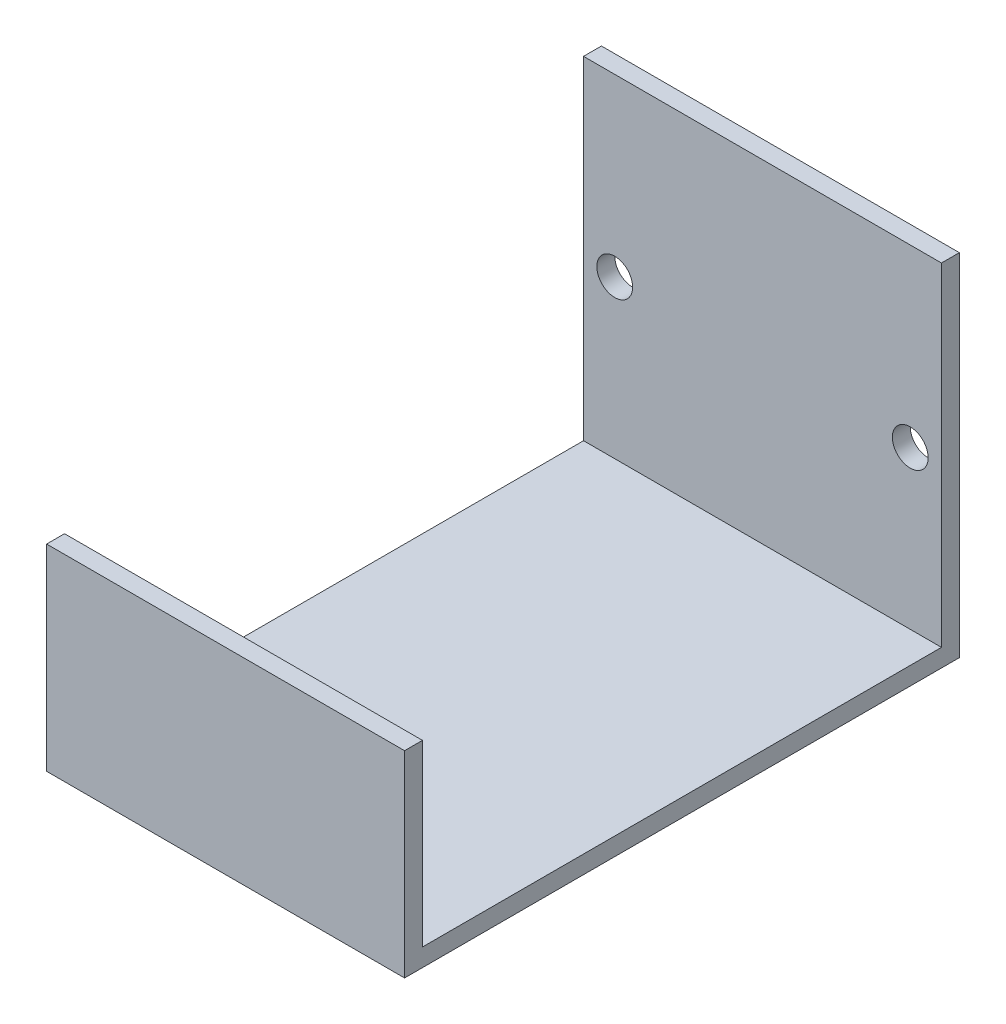
from build123d import *

# Parameters (mm, degrees)
SKETCH1_W           = 20
SKETCH1_H           = 19.6
SKETCH1_R           = 1
BOSS_EXTRUDE1_DEPTH = 1
SKETCH2_W           = 20
SKETCH2_H           = 1
BOSS_EXTRUDE2_DEPTH = 30
SKETCH3_W           = 20
SKETCH3_H           = 1
BOSS_EXTRUDE3_DEPTH = 10


with BuildPart() as part:
    # Sketch1 → Boss-Extrude1 (new body)
    with BuildSketch(Plane.XY):
        Rectangle(SKETCH1_W, SKETCH1_H)
        with Locations((-8.256, 0)):
            Circle(SKETCH1_R, mode=Mode.SUBTRACT)
        with Locations((8.256, 0)):
            Circle(SKETCH1_R, mode=Mode.SUBTRACT)
    extrude(amount=BOSS_EXTRUDE1_DEPTH)

    # Sketch2 → Boss-Extrude2 (add)
    with BuildSketch(Plane.XY.offset(1)):
        with Locations((0, -9.3)):
            Rectangle(SKETCH2_W, SKETCH2_H)
    extrude(amount=BOSS_EXTRUDE2_DEPTH)

    # Sketch3 → Boss-Extrude3 (add)
    with BuildSketch(Plane(origin=(0, -8.8, 0), x_dir=(1, 0, 0), z_dir=(0, 1, 0))):
        with Locations((0, -30.5)):
            Rectangle(SKETCH3_W, SKETCH3_H)
    extrude(amount=BOSS_EXTRUDE3_DEPTH)


solid = part.part
